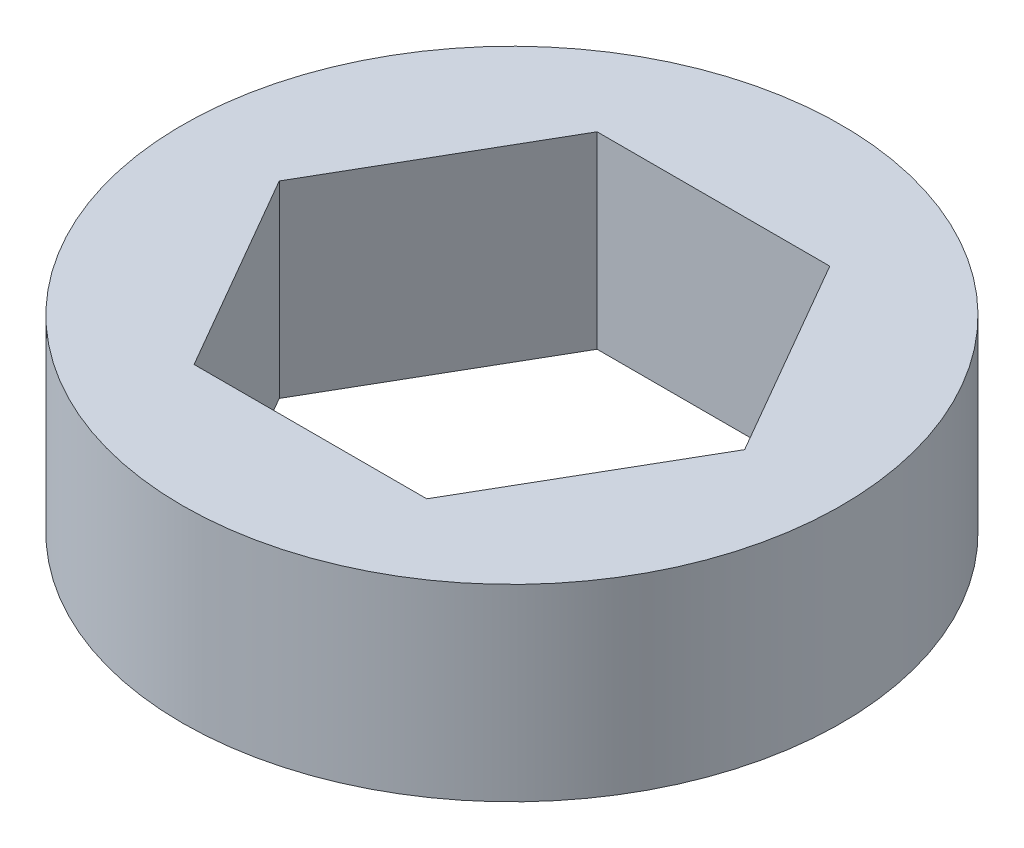
from build123d import *

# Parameters (mm, degrees)
SKETCH1_R           = 11.1125
BOSS_EXTRUDE1_DEPTH = 6.35


with BuildPart() as part:
    # Sketch1 → Boss-Extrude1 (new body)
    with BuildSketch(Plane(origin=(0, 0, 0), x_dir=(1, 0, 0), z_dir=(0, 1, 0))):
        Circle(SKETCH1_R)
        Polygon((7.845612808, 0), (3.922806404, 6.7945), (-3.922806404, 6.7945), (-7.845612808, 0), (-3.922806404, -6.7945), (3.922806404, -6.7945), align=None, mode=Mode.SUBTRACT)
    extrude(amount=BOSS_EXTRUDE1_DEPTH)


solid = part.part
